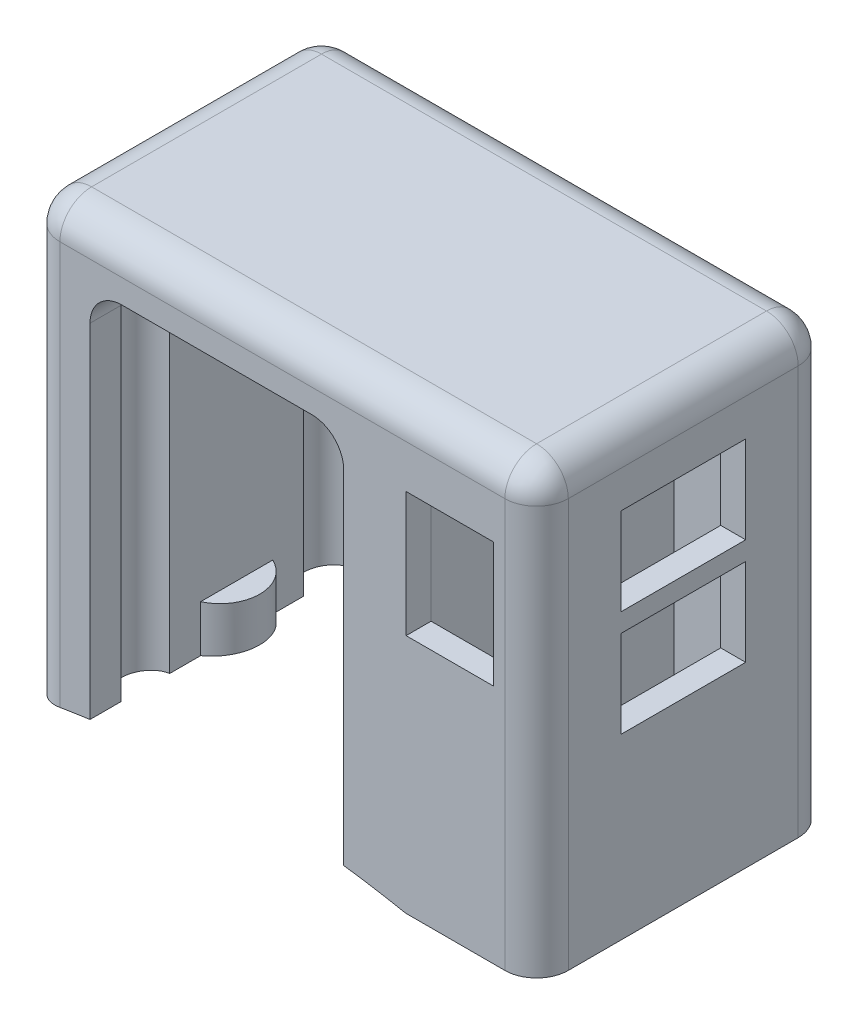
from build123d import *

# Parameters (mm, degrees)
SKETCH1_W           = 60.452
SKETCH1_H           = 71.12
BOSS_EXTRUDE1_DEPTH = 46.99
SKETCH2_W           = 40.64
SKETCH2_H           = 85.320739167
CUT_EXTRUDE1_DEPTH  = 46.99
SKETCH3_R           = 2.44475
CUT_EXTRUDE2_DEPTH  = 30.734
SKETCH5_R           = 6.35
BOSS_EXTRUDE4_DEPTH = 9.652
SKETCH3_5_R         = 2.44475
CUT_EXTRUDE3_DEPTH  = 38.1
FILLET1_R           = 5.08
SKETCH9_R           = 5.737107227
CUT_EXTRUDE6_DEPTH  = 4.572
SKETCH10_R          = 3.900639461
CUT_EXTRUDE10_DEPTH = 62.23
SKETCH8_R           = 152.4
CUT_EXTRUDE11_DEPTH = 55.372
SKETCH11_W          = 46.99
SKETCH11_H          = 65.461586673
BOSS_EXTRUDE6_DEPTH = 21
SKETCH12_W          = 17
SKETCH12_H          = 38.99
CUT_EXTRUDE12_DEPTH = 63
FILLET2_R           = 5.08
SKETCH25_W          = 20
SKETCH25_H          = 14
CUT_EXTRUDE13_DEPTH = 10
SKETCH26_W          = 14
SKETCH26_H          = 20
CUT_EXTRUDE14_DEPTH = 10


with BuildPart() as part:
    # Sketch1 → Boss-Extrude1 (new body)
    with BuildSketch(Plane.XY):
        with Locations((30.226, -35.56)):
            Rectangle(SKETCH1_W, SKETCH1_H)
    extrude(amount=BOSS_EXTRUDE1_DEPTH)

    # Sketch2 → Cut-Extrude1 (cut)
    with BuildSketch(Plane.XY.offset(46.99)):
        with Locations((30.226, -51.550369584)):
            Rectangle(SKETCH2_W, SKETCH2_H)
    extrude(amount=-CUT_EXTRUDE1_DEPTH, mode=Mode.SUBTRACT)

    # Sketch3 → Cut-Extrude2 (cut)
    with BuildSketch(Plane.XZ.offset(71.12)):
        with Locations((53.2003, 23.495)):
            Circle(SKETCH3_R)
        with Locations((7.2517, 23.495)):
            Circle(SKETCH3_R)
    extrude(amount=-CUT_EXTRUDE2_DEPTH, mode=Mode.SUBTRACT)

    # Sketch5 → Boss-Extrude4 (add)
    with BuildSketch(Plane.XZ.offset(71.12)):
        with Locations((7.2517, 23.495)):
            Circle(SKETCH5_R)
        with Locations((53.2003, 23.495)):
            Circle(SKETCH5_R)
    extrude(amount=-BOSS_EXTRUDE4_DEPTH)

    # Sketch3_5 → Cut-Extrude3 (cut)
    with BuildSketch(Plane.XZ.offset(71.12)):
        with Locations((53.2003, 23.495)):
            Circle(SKETCH3_5_R)
        with Locations((7.2517, 23.495)):
            Circle(SKETCH3_5_R)
    extrude(amount=-CUT_EXTRUDE3_DEPTH, mode=Mode.SUBTRACT)

    # Fillet1
    fillet1_edges = [part.edges().sort_by_distance(p)[0] for p in [
        (30.226, 0, 46.99),
        (50.546, -8.89, 23.495),
        (9.906, -8.89, 23.495),
        (0, -35.56, 46.99),
        (30.226, 0, 0),
        (0, -35.56, 0),
        (0, 0, 23.495),
    ]]
    fillet(fillet1_edges, radius=FILLET1_R)

    # Sketch9 → Cut-Extrude6 (cut)
    with BuildSketch(Plane.XZ.offset(8.89)):
        with Locations((30.226, 37.042280921)):
            Circle(SKETCH9_R)
        with Locations((30.226, 9.947719079)):
            Circle(SKETCH9_R)
    extrude(amount=-CUT_EXTRUDE6_DEPTH, mode=Mode.SUBTRACT)

    # Sketch10 → Cut-Extrude10 (cut)
    with BuildSketch(Plane(origin=(0, -71.12, 0), x_dir=(-1, 0, 0), z_dir=(0, -1, 0))):
        with Locations((-9.906, -38.126819309)):
            Circle(SKETCH10_R)
        with Locations((-9.906, -8.863180691)):
            Circle(SKETCH10_R)
        with Locations((-50.546, -38.126819309)):
            Circle(SKETCH10_R)
        with Locations((-50.546, -8.863180691)):
            Circle(SKETCH10_R)
    extrude(amount=-CUT_EXTRUDE10_DEPTH, mode=Mode.SUBTRACT)

    # Sketch8 → Cut-Extrude11 (cut)
    with BuildSketch(Plane.XY.offset(46.99)):
        with Locations((30.473524119, -219.963977846)):
            Circle(SKETCH8_R)
    extrude(amount=-CUT_EXTRUDE11_DEPTH, mode=Mode.SUBTRACT)

    # Sketch11 → Boss-Extrude6 (add)
    with BuildSketch(Plane(origin=(60.452, 0, 0), x_dir=(0, 0, -1), z_dir=(1, 0, 0))):
        with BuildLine():
            Line((-46.99, -5.08), (0, -5.08))
            ThreePointArc((0, -5.08), (-1.487897552, -1.487897552), (-5.08, 0))
            Line((-5.08, 0), (-41.91, 0))
            ThreePointArc((-41.91, 0), (-45.502102448, -1.487897552), (-46.99, -5.08))
        make_face()
        with Locations((-23.495, -37.810793336)):
            Rectangle(SKETCH11_W, SKETCH11_H)
    extrude(amount=BOSS_EXTRUDE6_DEPTH)

    # Sketch12 → Cut-Extrude12 (cut)
    with BuildSketch(Plane(origin=(0, -70.541586673, 0), x_dir=(-1, 0, 0), z_dir=(0, -1, 0))):
        with Locations((-68.952, -23.495)):
            Rectangle(SKETCH12_W, SKETCH12_H)
    extrude(amount=-CUT_EXTRUDE12_DEPTH, mode=Mode.SUBTRACT)

    # Fillet2
    fillet2_edges = [part.edges().sort_by_distance(p)[0] for p in [
        (81.452, -1.487897552, 45.502102448),
        (81.452, -37.810793337, 46.99),
        (81.452, -37.810793337, 0),
        (81.452, -1.487897552, 1.487897552),
        (81.452, 0, 23.495),
    ]]
    fillet(fillet2_edges, radius=FILLET2_R)

    # Sketch25 → Cut-Extrude13 (cut)
    with BuildSketch(Plane(origin=(81.452, 0, 0), x_dir=(0, 0, -1), z_dir=(1, 0, 0))):
        with Locations((-23.49, -18)):
            Rectangle(SKETCH25_W, SKETCH25_H)
        with Locations((-23.49, -35)):
            Rectangle(SKETCH25_W, SKETCH25_H)
    extrude(amount=-CUT_EXTRUDE13_DEPTH, mode=Mode.SUBTRACT)

    # Sketch26 → Cut-Extrude14 (cut)
    with BuildSketch(Plane.XY.offset(46.99)):
        with Locations((67.546, -22)):
            Rectangle(SKETCH26_W, SKETCH26_H)
    extrude(amount=-CUT_EXTRUDE14_DEPTH, mode=Mode.SUBTRACT)


solid = part.part
